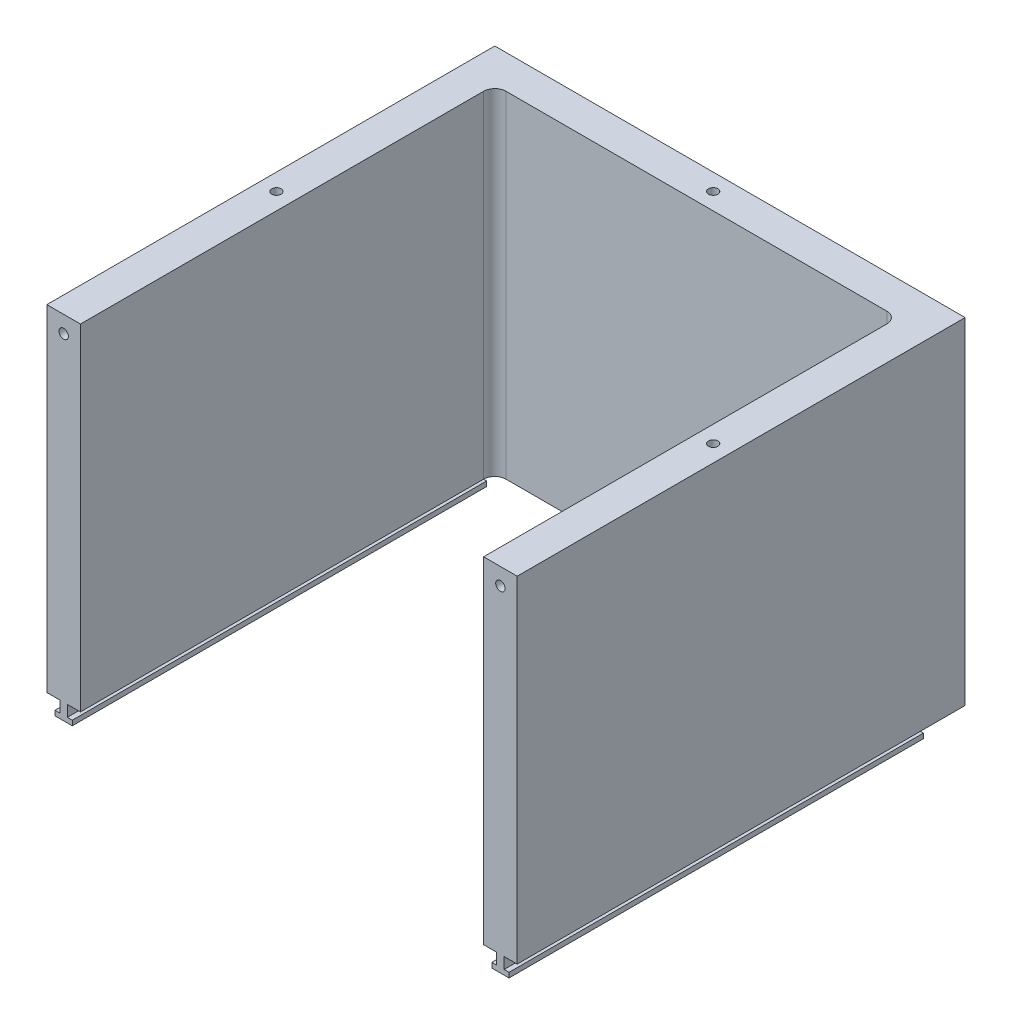
from build123d import *

# Parameters (mm, degrees)
BOSS_EXTRUDE1_DEPTH = 225
BOSS_EXTRUDE2_DEPTH = 10
SKETCH6_W           = 210
SKETCH6_H           = 200
BOSS_EXTRUDE3_DEPTH = 15
SKETCH5_R           = 2.1
CUT_EXTRUDE1_DEPTH  = 4.5
SKETCH10_W          = 210
SKETCH10_H          = 200
BOSS_EXTRUDE4_DEPTH = 40
SKETCH11_R          = 5
BOSS_EXTRUDE5_DEPTH = 5
BOSS_EXTRUDE5_TAPER = 5
SKETCH13_W          = 185
SKETCH13_H          = 10
BOSS_EXTRUDE6_DEPTH = 47.5
SKETCH14_W          = 185
SKETCH14_H          = 10
BOSS_EXTRUDE7_DEPTH = 47.5
SKETCH7_W           = 21
SKETCH7_H           = 10.25
CUT_EXTRUDE2_DEPTH  = 15
SKETCH15_R          = 2.1
CUT_EXTRUDE4_DEPTH  = 6
BOSS_EXTRUDE8_DEPTH = 185
FILLET1_R           = 5


with BuildPart() as part:
    # Sketch2 → Boss-Extrude1 (new body)
    with BuildSketch(Plane(origin=(0, 0, 0), x_dir=(1, 0, 0), z_dir=(0, 1, 0))):
        Polygon((-90, 0), (90, 0), (90, -185), (105, -185), (105, 15), (-105, 15), (-105, -185), (-90, -185), align=None)
    extrude(amount=BOSS_EXTRUDE1_DEPTH)

    # Sketch3 → Boss-Extrude2 (add)
    with BuildSketch(Plane(origin=(0, 10, 0), x_dir=(1, 0, 0), z_dir=(0, 1, 0))):
        Polygon((-90, -185), (-22.5, -185), (-22.5, -10), (22.5, -10), (22.5, -185), (90, -185), (90, 0), (-90, 0), align=None)
    extrude(amount=BOSS_EXTRUDE2_DEPTH)

    # Sketch6 → Boss-Extrude3 (add)
    with BuildSketch(Plane.XZ):
        with Locations((0, 85)):
            Rectangle(SKETCH6_W, SKETCH6_H)
    extrude(amount=BOSS_EXTRUDE3_DEPTH)

    # Sketch5 → Cut-Extrude1 (cut)
    with BuildSketch(Plane.XY.offset(185)):
        with Locations((-97.5, 217.5)):
            Circle(SKETCH5_R)
        with Locations((97.5, 217.5)):
            Circle(SKETCH5_R)
        with Locations((-97.5, -7.5)):
            Circle(SKETCH5_R)
        with Locations((97.5, -7.5)):
            Circle(SKETCH5_R)
    extrude(amount=-CUT_EXTRUDE1_DEPTH, mode=Mode.SUBTRACT)

    # Sketch10 → Boss-Extrude4 (add)
    with BuildSketch(Plane.XZ.offset(15)):
        with Locations((0, 85)):
            Rectangle(SKETCH10_W, SKETCH10_H)
    extrude(amount=BOSS_EXTRUDE4_DEPTH)

    # Sketch11 → Boss-Extrude5 (add)
    with BuildSketch(Plane(origin=(0, 0, 0), x_dir=(1, 0, 0), z_dir=(0, 1, 0))):
        with Locations((0, -90)):
            Circle(SKETCH11_R)
    extrude(amount=BOSS_EXTRUDE5_DEPTH, taper=BOSS_EXTRUDE5_TAPER)

    # Sketch13 → Boss-Extrude6 (add)
    with BuildSketch(Plane.ZY.offset(-90)):
        with Locations((92.5, 5)):
            Rectangle(SKETCH13_W, SKETCH13_H)
    extrude(amount=BOSS_EXTRUDE6_DEPTH)

    # Sketch14 → Boss-Extrude7 (add)
    with BuildSketch(Plane(origin=(-90, 0, 0), x_dir=(0, 0, -1), z_dir=(1, 0, 0))):
        with Locations((-92.5, 5)):
            Rectangle(SKETCH14_W, SKETCH14_H)
    extrude(amount=BOSS_EXTRUDE7_DEPTH)

    # Sketch7 → Cut-Extrude2 (cut)
    with BuildSketch(Plane(origin=(0, 0, -15), x_dir=(-1, 0, 0), z_dir=(0, 0, -1))):
        with Locations((-32, 5.125)):
            Rectangle(SKETCH7_W, SKETCH7_H)
    extrude(amount=-CUT_EXTRUDE2_DEPTH, mode=Mode.SUBTRACT)

    # Sketch15 → Cut-Extrude4 (cut)
    with BuildSketch(Plane(origin=(0, 225, 0), x_dir=(1, 0, 0), z_dir=(0, 1, 0))):
        with Locations((0, 7.5)):
            Circle(SKETCH15_R)
        with Locations((-97.5, -90)):
            Circle(SKETCH15_R)
        with Locations((97.5, -90)):
            Circle(SKETCH15_R)
    extrude(amount=-CUT_EXTRUDE4_DEPTH, mode=Mode.SUBTRACT)

    # Split1
    split(bisect_by=Plane.ZX.offset(75), keep=Keep.TOP)

    # Sketch16 → Boss-Extrude8 (add)
    with BuildSketch(Plane.XY.offset(185)):
        Polygon((-99.15, 75), (-95.85, 75), (-95.85, 70), (-93.65, 70), (-93.65, 67.8), (-101.35, 67.8), (-101.35, 70), (-99.15, 70), align=None)
        Polygon((101.35, 70), (99.15, 70), (99.15, 75), (95.85, 75), (95.85, 70), (93.65, 70), (93.65, 67.8), (101.35, 67.8), align=None)
    extrude(amount=-BOSS_EXTRUDE8_DEPTH)

    # Fillet1
    fillet1_edges = [part.edges().sort_by_distance(p)[0] for p in [
        (90, 150, 0),
        (-90, 150, 0),
    ]]
    fillet(fillet1_edges, radius=FILLET1_R)


solid = part.part
